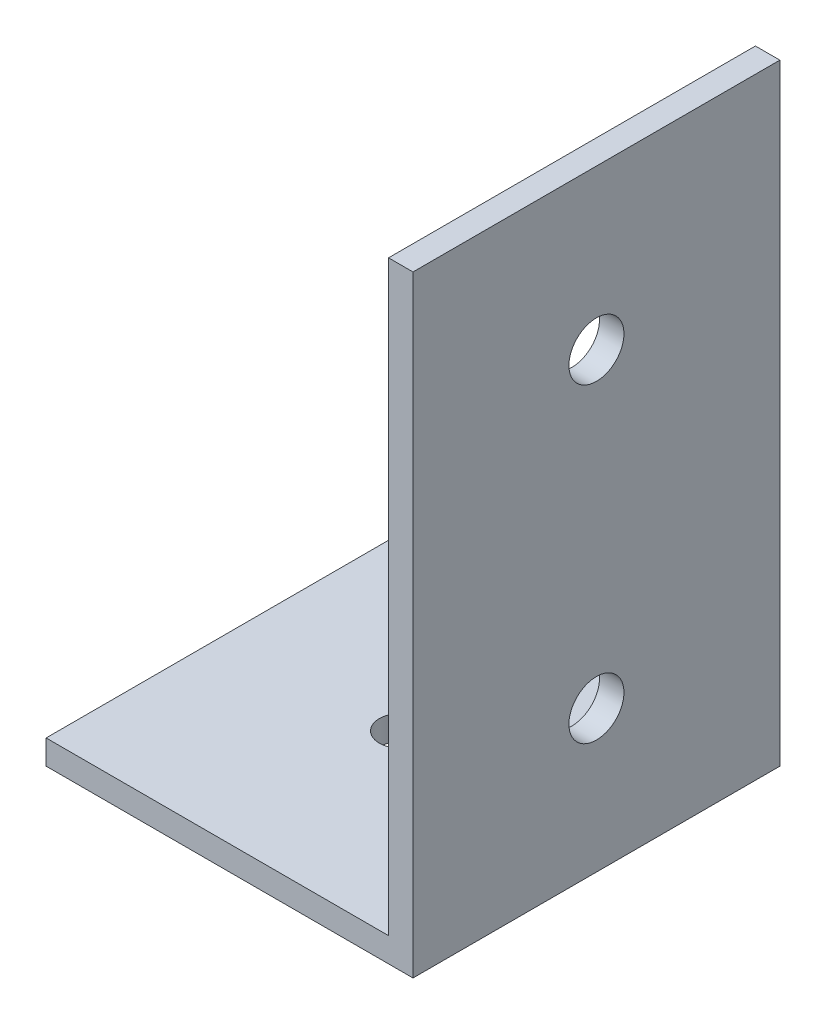
from build123d import *

# Parameters (mm, degrees)
ESTRUSIONE_ESTRUSIONE1_DEPTH = 30
SCHIZZO2_R                   = 2.25
TAGLIO_ESTRUSIONE1_DEPTH     = 3
SCHIZZO3_R                   = 1.75
TAGLIO_ESTRUSIONE2_DEPTH     = 3


with BuildPart() as part:
    # Schizzo1 → Estrusione-Estrusione1 (new body)
    with BuildSketch(Plane.XY):
        Polygon((0, 0), (-30, 0), (-30, 2), (-2, 2), (-2, 50), (0, 50), align=None)
    extrude(amount=ESTRUSIONE_ESTRUSIONE1_DEPTH)

    # Schizzo2 → Taglio-Estrusione1 (cut, through all)
    with BuildSketch(Plane.ZY.offset(2)):
        with Locations((15, 37)):
            Circle(SCHIZZO2_R)
        with Locations((15, 11.6)):
            Circle(SCHIZZO2_R)
    extrude(amount=-TAGLIO_ESTRUSIONE1_DEPTH, mode=Mode.SUBTRACT)

    # Schizzo3 → Taglio-Estrusione2 (cut, through all)
    with BuildSketch(Plane(origin=(0, 2, 0), x_dir=(1, 0, 0), z_dir=(0, 1, 0))):
        with Locations((-16, -15)):
            Circle(SCHIZZO3_R)
    extrude(amount=-TAGLIO_ESTRUSIONE2_DEPTH, mode=Mode.SUBTRACT)


solid = part.part
